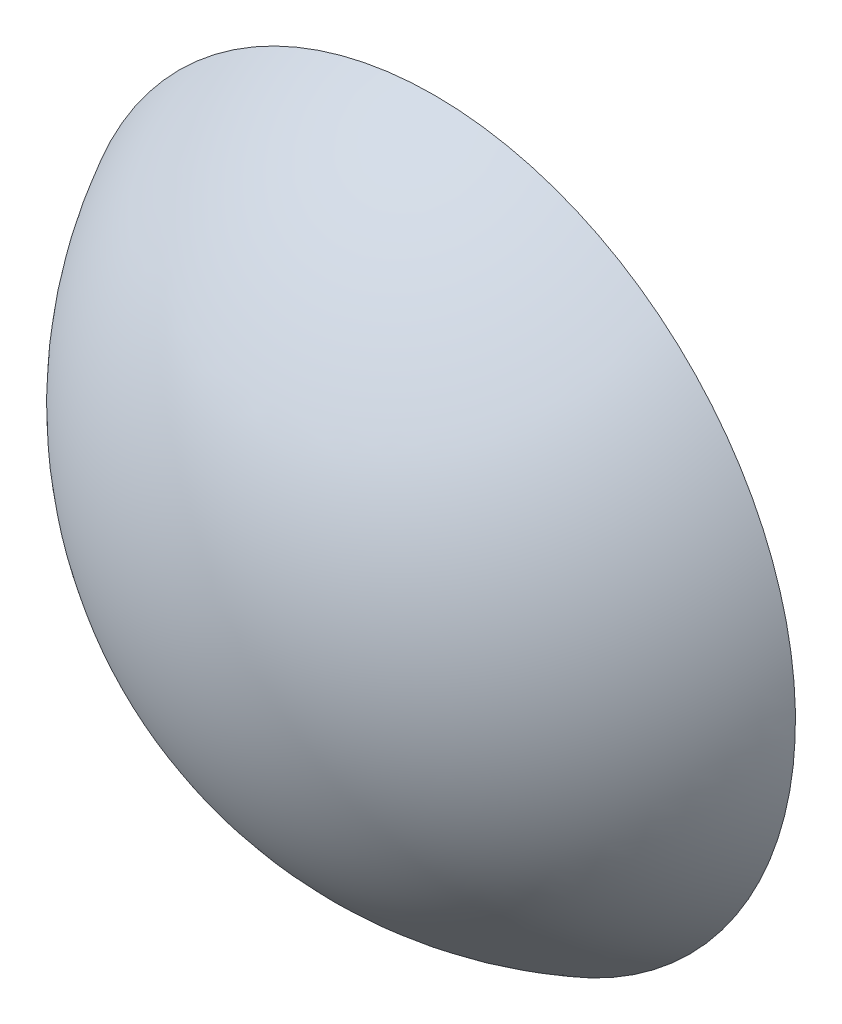
from build123d import *


with BuildPart() as part:
    # Sketch1 → Revolve1 (revolve)
    with BuildSketch(Plane.YZ):
        with BuildLine():
            Line((0, 4.381924265), (8.457207857, 4.381924265))
            ThreePointArc((8.457207857, 4.381924265), (4.949131054, 8.138287707), (0, 9.525))
            Line((0, 9.525), (0, 4.381924265))
        make_face()
    revolve(axis=Axis((0, 0, 4.381924265), (0, 0, 1)))


solid = part.part
